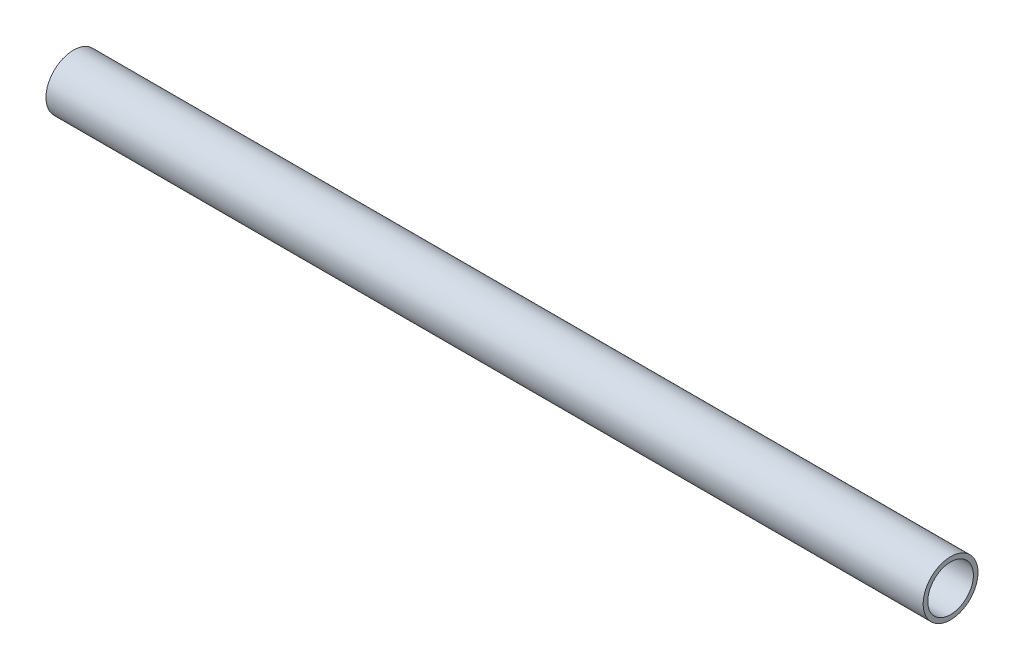
from build123d import *

# Parameters (mm, degrees)
SKETCH11_R              = 6.35
SKETCH11_R_2            = 5.2832
PIPE_0_5_SCH_40_1_DEPTH = 203.203520879


with BuildPart() as part:
    # Sketch11 → Pipe 0.5 SCH 40(1) (new body)
    with BuildSketch(Plane(origin=(17.622221572, 1527.512796137, 0), x_dir=(0, 1, 0), z_dir=(1, 0, 0))):
        Circle(SKETCH11_R)
        Circle(SKETCH11_R_2, mode=Mode.SUBTRACT)
    extrude(amount=PIPE_0_5_SCH_40_1_DEPTH)


solid = part.part
